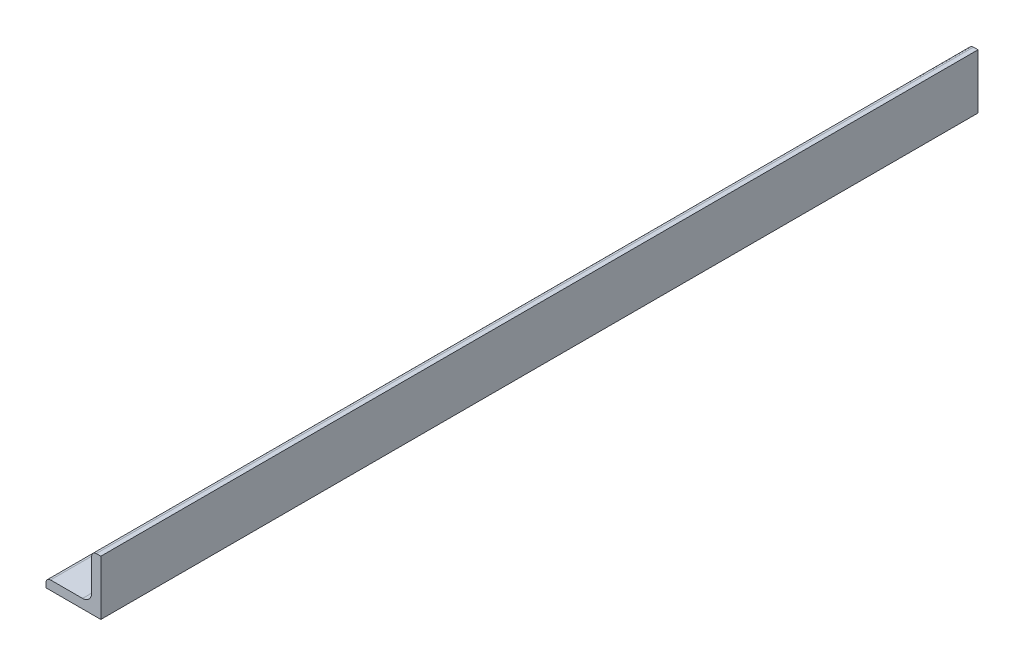
from build123d import *

# Parameters (mm, degrees)
BOSS_EXTRUDE1_DEPTH = 152.4


with BuildPart() as part:
    # Sketch2 → Boss-Extrude1 (new, symmetric)
    with BuildSketch(Plane.XY):
        with BuildLine():
            Line((-9.525, -9.525), (9.525, -9.525))
            Line((9.525, -9.525), (9.525, 9.525))
            Line((9.525, 9.525), (7.9375, 9.525))
            ThreePointArc((7.9375, 9.525), (6.814967985, 9.060032015), (6.35, 7.9375))
            Line((6.35, 7.9375), (6.35, -3.175))
            ThreePointArc((6.35, -3.175), (5.42006403, -5.42006403), (3.175, -6.35))
            Line((3.175, -6.35), (-7.9375, -6.35))
            ThreePointArc((-7.9375, -6.35), (-9.060032015, -6.814967985), (-9.525, -7.9375))
            Line((-9.525, -7.9375), (-9.525, -9.525))
        make_face()
    extrude(amount=BOSS_EXTRUDE1_DEPTH, both=True)


solid = part.part
